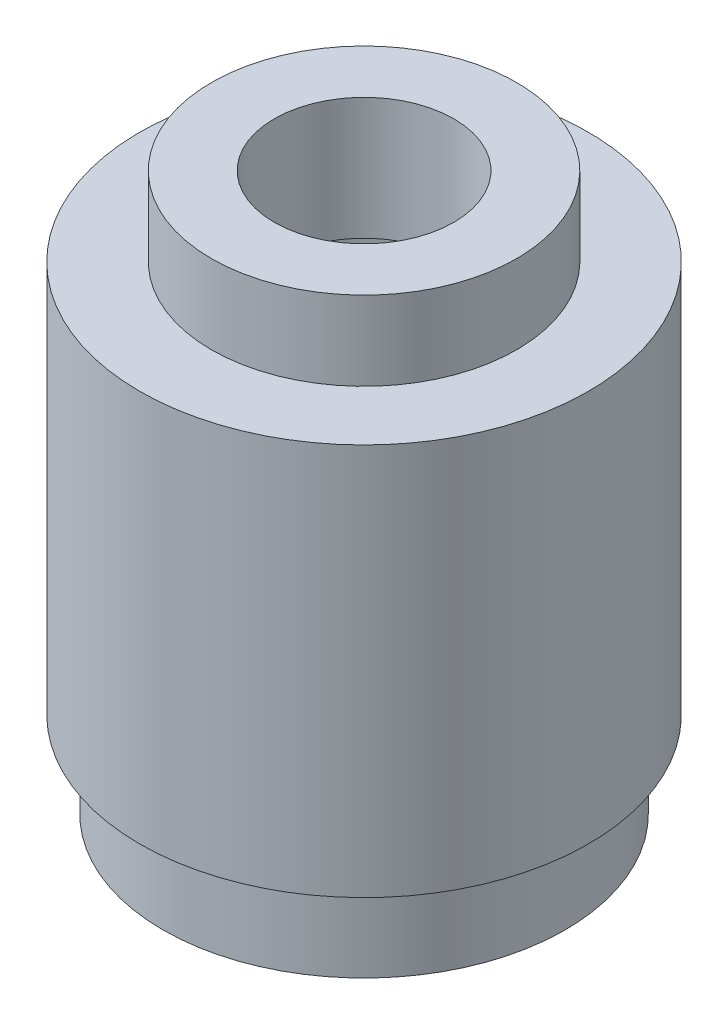
from build123d import *


with BuildPart() as part:
    # Sketch1 → Revolve1 (revolve)
    with BuildSketch(Plane.XY):
        Polygon((2.69875, -4.2291), (2.69875, -1.9431), (3.46075, -1.9431), (3.46075, 3.4671), (1.5875, 3.4671), (1.5875, 5.6261), (2.69875, 5.6261), (2.69875, 4.2291), (3.96875, 4.2291), (3.96875, -2.7051), (3.556, -2.7051), (3.556, -4.2291), align=None)
    revolve(axis=Axis((0, 42.294346237, 0), (0, -1, 0)))


solid = part.part
